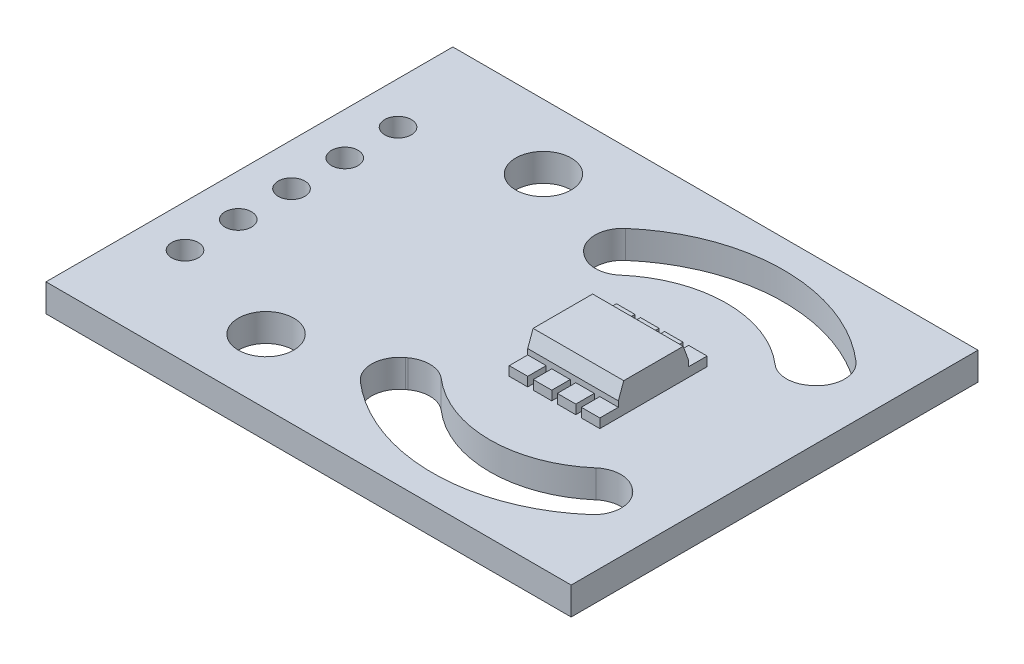
from build123d import *

# Parameters (mm, degrees)
SKETCH1_W             = 28.4
SKETCH1_H             = 22
BOSS_EXTRUDE1_DEPTH   = 1.5
SKETCH2_R             = 1.5
SKETCH2_R_2           = 0.72
CUT_EXTRUDE1_DEPTH    = 2.5
FILLET1_R             = 1.5
SKETCH3_W             = 4.9
SKETCH3_H             = 3.8
BOSS_EXTRUDE2_DEPTH   = 1.6
CHAMFER1_SIZE         = 0.8
CHAMFER1_SIZE2        = 0.291176187
CHAMFER1_PART_2_SIZE  = 0.8
CHAMFER1_PART_2_SIZE2 = 0.291176187
SKETCH6_W             = 1
SKETCH6_H             = 1
BOSS_EXTRUDE3_DEPTH   = 0.5


with BuildPart() as part:
    # Sketch1 → Boss-Extrude1 (new body)
    with BuildSketch(Plane(origin=(0, 0, 0), x_dir=(1, 0, 0), z_dir=(0, 1, 0))):
        Rectangle(SKETCH1_W, SKETCH1_H)
    extrude(amount=BOSS_EXTRUDE1_DEPTH)

    # Sketch2 → Cut-Extrude1 (cut, through all)
    with BuildSketch(Plane(origin=(0, 1.5, 0), x_dir=(1, 0, 0), z_dir=(0, 1, 0))):
        with Locations(Location((-5.8, 7.5, 0), (0, 0, 270))):  # turned: the seam where the file's is
            Circle(SKETCH2_R)
        with Locations(Location((-5.8, -7.5, 0), (0, 0, 270))):  # turned: the seam where the file's is
            Circle(SKETCH2_R)
        with Locations(Location((-11.92285327, 5.76, 0), (0, 0, 270))):  # turned: the seam where the file's is
            Circle(SKETCH2_R_2)
        with Locations(Location((-11.92285327, 2.88, 0), (0, 0, 270))):  # turned: the seam where the file's is
            Circle(SKETCH2_R_2)
        with Locations(Location((-11.92285327, 0, 0), (0, 0, 270))):  # turned: the seam where the file's is
            Circle(SKETCH2_R_2)
        with Locations(Location((-11.92285327, -2.88, 0), (0, 0, 270))):  # turned: the seam where the file's is
            Circle(SKETCH2_R_2)
        with Locations(Location((-11.92285327, -5.76, 0), (0, 0, 270))):  # turned: the seam where the file's is
            Circle(SKETCH2_R_2)
        with BuildLine():
            Line((-2.3, 5.830951895), (0.2, 3.994996871))
            ThreePointArc((0.2, 3.994996871), (5.2, 6.4), (10.2, 3.994996871))
            Line((10.2, 3.994996871), (12.7, 5.830951895))
            ThreePointArc((12.7, 5.830951895), (5.2, 9.5), (-2.3, 5.830951895))
        make_face()
        with BuildLine():
            Line((10.2, -3.994996871), (12.7, -5.830951895))
            ThreePointArc((12.7, -5.830951895), (5.2, -9.5), (-2.3, -5.830951895))
            Line((-2.3, -5.830951895), (0.2, -3.994996871))
            ThreePointArc((0.2, -3.994996871), (5.2, -6.4), (10.2, -3.994996871))
        make_face()
    extrude(amount=-CUT_EXTRUDE1_DEPTH, mode=Mode.SUBTRACT)

    # Fillet1
    fillet1_edges = [part.edges().sort_by_distance(p)[0] for p in [
        (-2.3, 0.75, -5.830951895),
        (12.7, 0.75, -5.830951895),
        (10.2, 0.75, -3.994996871),
        (0.2, 0.75, -3.994996871),
        (0.2, 0.75, 3.994996871),
        (10.2, 0.75, 3.994996871),
        (12.7, 0.75, 5.830951895),
        (-2.3, 0.75, 5.830951895),
    ]]
    fillet(fillet1_edges, radius=FILLET1_R)

    # Sketch3 → Boss-Extrude2 (add)
    with BuildSketch(Plane(origin=(0, 1.5, 0), x_dir=(1, 0, 0), z_dir=(0, 1, 0))):
        with Locations((5.2, 0)):
            Rectangle(SKETCH3_W, SKETCH3_H)
    extrude(amount=BOSS_EXTRUDE2_DEPTH)

    # Chamfer1
    chamfer1_edges = [part.edges().sort_by_distance(p)[0] for p in [
        (5.2, 3.1, 1.9),
    ]]
    chamfer1_side = [part.faces().sort_by_distance(p)[0] for p in [
        (5.2, 2.3, 1.9),
    ]]
    chamfer(chamfer1_edges, length=CHAMFER1_SIZE, length2=CHAMFER1_SIZE2, reference=chamfer1_side[0])

    # Chamfer1 part 2
    chamfer1_part_2_edges = [part.edges().sort_by_distance(p)[0] for p in [
        (5.2, 3.1, -1.9),
    ]]
    chamfer1_part_2_side = [part.faces().sort_by_distance(p)[0] for p in [
        (5.2, 2.3, -1.9),
    ]]
    chamfer(chamfer1_part_2_edges, length=CHAMFER1_PART_2_SIZE, length2=CHAMFER1_PART_2_SIZE2, reference=chamfer1_part_2_side[0])

    # Sketch6 → Boss-Extrude3 (add)
    with BuildSketch(Plane(origin=(0, 1.5, 0), x_dir=(1, 0, 0), z_dir=(0, 1, 0))):
        with Locations((3.25, -2.4)):
            Rectangle(SKETCH6_W, SKETCH6_H)
        with Locations((3.25, 2.4)):
            Rectangle(SKETCH6_W, SKETCH6_H)
        with Locations((4.55, -2.4)):
            Rectangle(SKETCH6_W, SKETCH6_H)
        with Locations((4.55, 2.4)):
            Rectangle(SKETCH6_W, SKETCH6_H)
        with Locations((5.85, -2.4)):
            Rectangle(SKETCH6_W, SKETCH6_H)
        with Locations((5.85, 2.4)):
            Rectangle(SKETCH6_W, SKETCH6_H)
        with Locations((7.15, -2.4)):
            Rectangle(SKETCH6_W, SKETCH6_H)
        with Locations((7.15, 2.4)):
            Rectangle(SKETCH6_W, SKETCH6_H)
    extrude(amount=BOSS_EXTRUDE3_DEPTH)


solid = part.part
